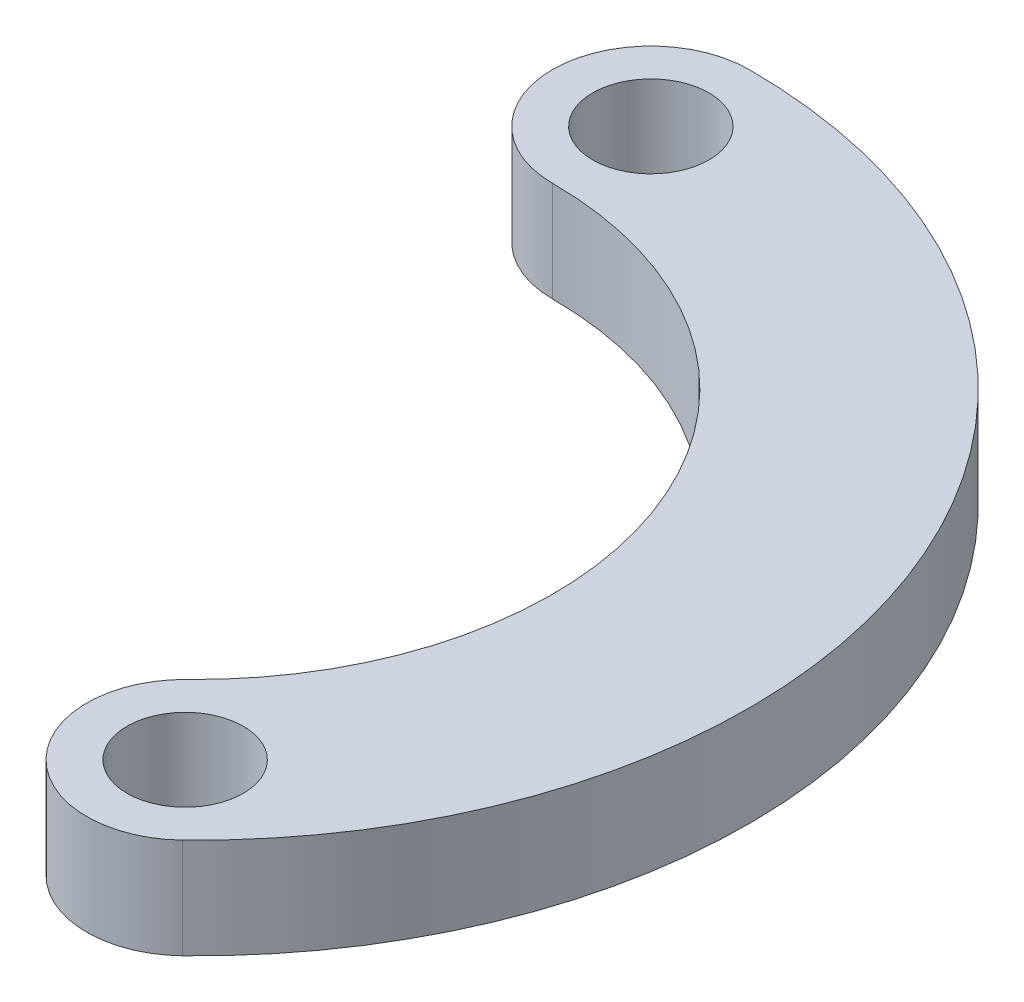
from build123d import *

# Parameters (mm, degrees)
ESTRUSIONE_ESTRUSIONE1_DEPTH = 2.8
SCHIZZO3_R                   = 1.625
TAGLIO_ESTRUSIONE1_DEPTH     = 3.8


with BuildPart() as part:
    # Schizzo1 → Estrusione-Estrusione1 (new body)
    with BuildSketch(Plane(origin=(0, 0, 0), x_dir=(1, 0, 0), z_dir=(0, 1, 0))):
        with BuildLine():
            Line((0, 12.183185174), (0, 9.95))
            ThreePointArc((0, 9.95), (7.035712473, 7.035712473), (9.95, 0))
            ThreePointArc((9.95, 0), (9.159023292, -3.887774728), (6.911850786, -7.157431013))
            ThreePointArc((6.911850786, -7.157431013), (6.843976854, -11.045925983), (10.732471824, -11.113799915))
            ThreePointArc((10.732471824, -11.113799915), (14.221799986, -6.036795935), (15.45, 0))
            ThreePointArc((15.45, 0), (10.924799769, 10.924799769), (0, 15.45))
            Line((0, 15.45), (0, 12.183185174))
        make_face()
        with BuildLine():
            ThreePointArc((0, 15.45), (-2.75, 12.7), (0, 9.95))
            Line((0, 9.95), (0, 12.183185174))
            Line((0, 12.183185174), (0, 15.45))
        make_face()
    extrude(amount=-ESTRUSIONE_ESTRUSIONE1_DEPTH)

    # Schizzo3 → Taglio-Estrusione1 (cut, through all)
    with BuildSketch(Plane(origin=(0, 0, 0), x_dir=(1, 0, 0), z_dir=(0, 1, 0))):
        with Locations((0, 12.7)):
            Circle(SCHIZZO3_R)
        with Locations((8.822161305, -9.135615464)):
            Circle(SCHIZZO3_R)
    extrude(amount=-TAGLIO_ESTRUSIONE1_DEPTH, mode=Mode.SUBTRACT)


solid = part.part
